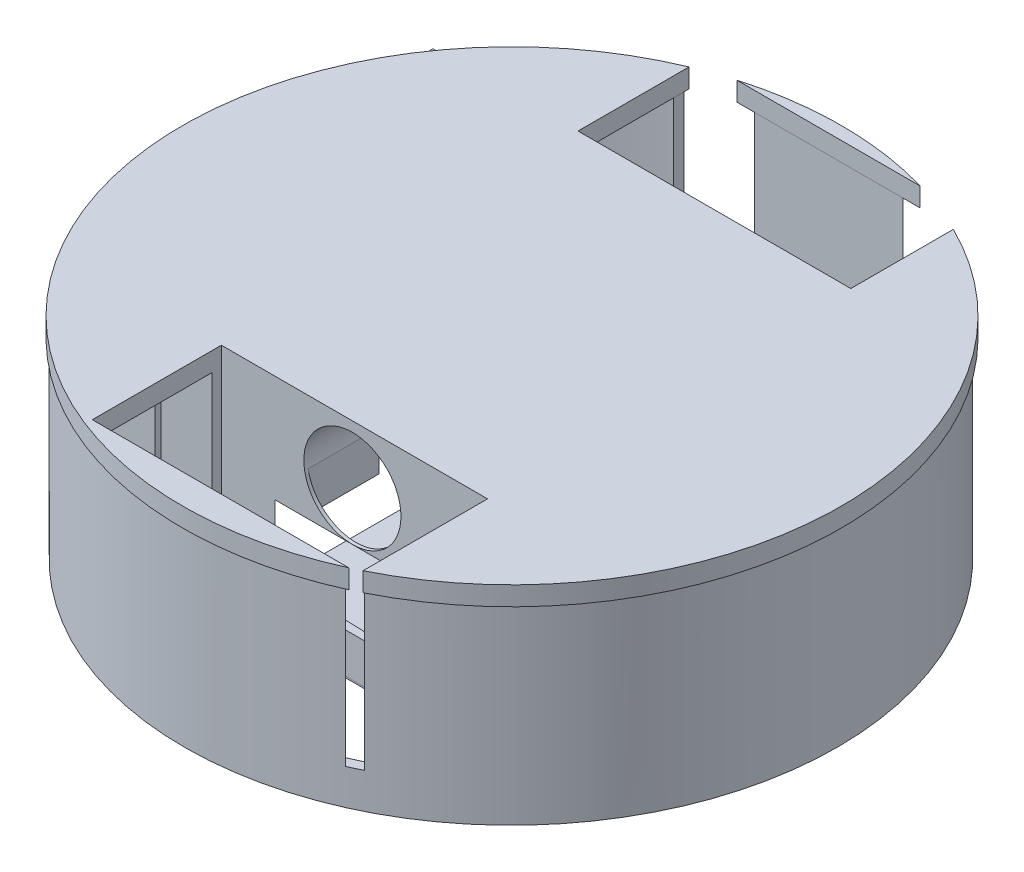
from build123d import *

# Parameters (mm, degrees)
MOTORHOLDERSSKETCH_R          = 23.41
MOTORHOLDERS_DEPTH            = 80
MOTORHOLDERS_DEPTH_BACK       = 80
SKETCH4_W                     = 262.774983374
SKETCH4_H                     = 153.112553215
CUT_EXTRUDE1_DEPTH            = 26
SKETCH6_W                     = 40.569681466
SKETCH6_H                     = 13.420779119
POWERBANKHOLDERS_DEPTH        = 30
POWERBANKHOLDERS_DEPTH_BACK   = 59
SKETCH6_W_2                   = 24.337910208
SKETCH6_H_2                   = 38.261259506
SKETCH6_W_3                   = 13.389321538
SKETCH6_H_3                   = 10.347679347
POWERBANKHOLDERS_2_DEPTH      = 30
POWERBANKHOLDERS_2_DEPTH_BACK = 59
SKETCH6_W_4                   = 55.674763771
SKETCH6_H_4                   = 37.111507406
SKETCH6_W_5                   = 12.844328805
SKETCH6_H_5                   = 18.336479725
SKETCH6_W_6                   = 12.407504742
SKETCH6_H_6                   = 16.443461188
POWERBANKHOLDERS_3_DEPTH      = 30
POWERBANKHOLDERS_3_DEPTH_BACK = 59
SKETCH6_W_7                   = 56.474336521
SKETCH6_H_7                   = 35.272094794
SKETCH6_W_8                   = 11.134493861
SKETCH6_H_8                   = 18.035399163
SKETCH6_W_9                   = 16.537391536
SKETCH6_H_9                   = 14.436538778
POWERBANKHOLDERS_4_DEPTH      = 30
POWERBANKHOLDERS_4_DEPTH_BACK = 59
SKETCH6_W_10                  = 28.150495439
SKETCH6_H_10                  = 24.933985152
SKETCH6_W_11                  = 10.177859407
SKETCH6_H_11                  = 9.83070569
POWERBANKHOLDERS_5_DEPTH      = 30
POWERBANKHOLDERS_5_DEPTH_BACK = 59
SKETCH6_W_12                  = 30.670744753
SKETCH6_H_12                  = 26.330219561
SKETCH6_W_13                  = 9.898416255
SKETCH6_H_13                  = 10.635603546
POWERBANKHOLDERS_6_DEPTH      = 30
POWERBANKHOLDERS_6_DEPTH_BACK = 59
SKETCH21_R                    = 138.5
BOTTOMPLATE_DEPTH             = 5
BOTTOMPLATE_DEPTH_BACK        = 3
SKETCH23_W                    = 82.936115801
SKETCH23_H                    = 87.063331284
MOTORMOUNTINGSUPPORT1_DEPTH   = 6
SKETCH24_W                    = 62.643465408
SKETCH24_H                    = 86.363062387
MOTORMOUNTINGSUPPOR2_DEPTH    = 6
SKETCH17_R                    = 2.1
SKETCH17_R_2                  = 7.5
MOTORHOLES1_DEPTH             = 31.5
SKETCH19_R                    = 2.1
SKETCH19_R_2                  = 7.5
CUT_EXTRUDE4_DEPTH            = 30
SKETCH29_W                    = 154.635205036
SKETCH29_H                    = 84.131588093
SKETCH29_W_2                  = 26
SKETCH29_H_2                  = 19.212652328
BOSS_EXTRUDE8_DEPTH           = 3
SKETCH28_W                    = 66.387115975
SKETCH28_H                    = 157.698901517
CELLPHONEPLATE_DEPTH          = 1.5
CELLPHONEPLATE_DEPTH_BACK     = 2.5
POWERBANKCUT_DEPTH            = 44.404272
MOTORHOLDEREXTRUDESKETCH_R    = 20.415
MOTORHOLDERCUT_DEPTH          = 77
MOTORHOLDERCUT_DEPTH_BACK     = 77
LABEL_DEPTH                   = 1
SKETCH42_R                    = 54.5
SKETCH42_R_2                  = 42
CUT_EXTRUDE10_DEPTH           = 10
CUT_EXTRUDE10_DEPTH_BACK      = 5
SKETCH43_R                    = 54.5
SKETCH43_R_2                  = 42
CUT_EXTRUDE11_DEPTH           = 5
CUT_EXTRUDE11_DEPTH_BACK      = 5
SKETCH47_R                    = 137.263845686
SKETCH47_R_2                  = 133.081286055
BOSS_EXTRUDE9_DEPTH           = 80
SKETCH46_W                    = 111.865332741
SKETCH46_H                    = 54.241690417
SKETCH46_W_2                  = 114.657260807
SKETCH46_H_2                  = 51.893411638
CUT_EXTRUDE13_DEPTH           = 65
CUT_EXTRUDE13_DEPTH_BACK      = 45


with BuildPart() as part:
    # MotorHoldersSketch → MotorHolders (new body, two sides)
    with BuildSketch(Plane.XY) as motorholders_sk:
        with Locations((170, 0)):
            Circle(MOTORHOLDERSSKETCH_R)
    extrude(amount=MOTORHOLDERS_DEPTH)
    extrude(motorholders_sk.sketch, amount=-MOTORHOLDERS_DEPTH_BACK)

    # Sketch4 → Cut-Extrude1 (cut)
    with BuildSketch(Plane(origin=(0, 0, 0), x_dir=(1, 0, 0), z_dir=(0, 1, 0))):
        with Locations((89.893628689, 0.176832173)):
            Rectangle(SKETCH4_W, SKETCH4_H)
    extrude(amount=-CUT_EXTRUDE1_DEPTH, mode=Mode.SUBTRACT)


with BuildPart() as body_2:
    # Sketch6 → PowerBankHolders (new body, two sides)
    with BuildSketch(Plane(origin=(170, -34.829272125, 0), x_dir=(-1, 0, 0), z_dir=(0, -1, 0))) as powerbankholders_sk:
        with Locations((98.656261503, 70.613788094)):
            Rectangle(SKETCH6_W, SKETCH6_H)
    extrude(amount=POWERBANKHOLDERS_DEPTH)
    extrude(powerbankholders_sk.sketch, amount=-POWERBANKHOLDERS_DEPTH_BACK)



with BuildPart() as body_3:
    # Sketch6 → PowerBankHolders 2 (new body, two sides)
    with BuildSketch(Plane(origin=(170, -34.829272125, 0), x_dir=(-1, 0, 0), z_dir=(0, -1, 0))) as powerbankholders_2_sk:
        with Locations((90.713991437, -60.661147317)):
            Rectangle(SKETCH6_W_2, SKETCH6_H_2)
        with Locations((95.188696255, -66.823906317)):
            Rectangle(SKETCH6_W_3, SKETCH6_H_3, mode=Mode.SUBTRACT)
    extrude(amount=POWERBANKHOLDERS_2_DEPTH)
    extrude(powerbankholders_2_sk.sketch, amount=-POWERBANKHOLDERS_2_DEPTH_BACK)


with BuildPart() as body_4:
    # Sketch6 → PowerBankHolders 3 (new body, two sides)
    with BuildSketch(Plane(origin=(170, -34.829272125, 0), x_dir=(-1, 0, 0), z_dir=(0, -1, 0))) as powerbankholders_3_sk:
        with Locations((47.827743092, 59.306920349)):
            Rectangle(SKETCH6_W_4, SKETCH6_H_4)
        with Locations((34.93306737, 60.00949088)):
            Rectangle(SKETCH6_W_5, SKETCH6_H_5, mode=Mode.SUBTRACT)
        with Locations((60.073413265, 59.541495334)):
            Rectangle(SKETCH6_W_6, SKETCH6_H_6, mode=Mode.SUBTRACT)
    extrude(amount=POWERBANKHOLDERS_3_DEPTH)
    extrude(powerbankholders_3_sk.sketch, amount=-POWERBANKHOLDERS_3_DEPTH_BACK)


with BuildPart() as body_5:
    # Sketch6 → PowerBankHolders 4 (new body, two sides)
    with BuildSketch(Plane(origin=(170, -34.829272125, 0), x_dir=(-1, 0, 0), z_dir=(0, -1, 0))) as powerbankholders_4_sk:
        with Locations((48.322417758, -61.807610384)):
            Rectangle(SKETCH6_W_7, SKETCH6_H_7)
        with Locations((37.73953158, -63.792391966)):
            Rectangle(SKETCH6_W_8, SKETCH6_H_8, mode=Mode.SUBTRACT)
        with Locations((59.979410768, -62.645522509)):
            Rectangle(SKETCH6_W_9, SKETCH6_H_9, mode=Mode.SUBTRACT)
    extrude(amount=POWERBANKHOLDERS_4_DEPTH)
    extrude(powerbankholders_4_sk.sketch, amount=-POWERBANKHOLDERS_4_DEPTH_BACK)


with BuildPart() as body_6:
    # Sketch6 → PowerBankHolders 5 (new body, two sides)
    with BuildSketch(Plane(origin=(170, -34.829272125, 0), x_dir=(-1, 0, 0), z_dir=(0, -1, 0))) as powerbankholders_5_sk:
        with Locations((-34.775388772, -66.976665205)):
            Rectangle(SKETCH6_W_10, SKETCH6_H_10)
        with Locations((-36.725173705, -67.894738702)):
            Rectangle(SKETCH6_W_11, SKETCH6_H_11, mode=Mode.SUBTRACT)
    extrude(amount=POWERBANKHOLDERS_5_DEPTH)
    extrude(powerbankholders_5_sk.sketch, amount=-POWERBANKHOLDERS_5_DEPTH_BACK)


with BuildPart() as body_7:
    # Sketch6 → PowerBankHolders 6 (new body, two sides)
    with BuildSketch(Plane(origin=(170, -34.829272125, 0), x_dir=(-1, 0, 0), z_dir=(0, -1, 0))) as powerbankholders_6_sk:
        with Locations((-33.722690809, 64.697564271)):
            Rectangle(SKETCH6_W_12, SKETCH6_H_12)
        with Locations((-36.585452129, 63.859928969)):
            Rectangle(SKETCH6_W_13, SKETCH6_H_13, mode=Mode.SUBTRACT)
    extrude(amount=POWERBANKHOLDERS_6_DEPTH)
    extrude(powerbankholders_6_sk.sketch, amount=-POWERBANKHOLDERS_6_DEPTH_BACK)

    # Sketch24 → MotorMountingSuppor2 (add)
    with BuildSketch(Plane(origin=(0, 0, -80), x_dir=(-1, 0, 0), z_dir=(0, 0, -1))):
        with Locations((-170.868787608, -23.94412431)):
            Rectangle(SKETCH24_W, SKETCH24_H)
    extrude(amount=-MOTORMOUNTINGSUPPOR2_DEPTH)

    # Sketch19 → Cut-Extrude4 (cut)
    with BuildSketch(Plane(origin=(0, 0, -80), x_dir=(-1, 0, 0), z_dir=(0, 0, -1))):
        with Locations((-185.5, 0)):
            Circle(SKETCH19_R)
        with Locations((-177.75, -13.42)):
            Circle(SKETCH19_R)
        with Locations((-162.25, -13.42)):
            Circle(SKETCH19_R)
        with Locations((-154.5, 0)):
            Circle(SKETCH19_R)
        with Locations((-162.25, 13.42)):
            Circle(SKETCH19_R)
        with Locations((-177.75, 13.42)):
            Circle(SKETCH19_R)
        with Locations((-170, 7)):
            Circle(SKETCH19_R_2)
    extrude(amount=-CUT_EXTRUDE4_DEPTH, mode=Mode.SUBTRACT)

    # Sketch29 → Boss-Extrude8 (add)
    with BuildSketch(Plane(origin=(219.058063185, 0, 0), x_dir=(0, 0, -1), z_dir=(1, 0, 0))):
        with Locations((-0.622085312, -21.859578752)):
            Rectangle(SKETCH29_W, SKETCH29_H)
        with Locations((-0.45071267, -38.546737855)):
            Rectangle(SKETCH29_W_2, SKETCH29_H_2, mode=Mode.SUBTRACT)
    extrude(amount=-BOSS_EXTRUDE8_DEPTH)

    # Sketch28 → CellPhonePlate (add, two sides)
    with BuildSketch(Plane(origin=(0, -64.829272125, 0), x_dir=(-1, 0, 0), z_dir=(0, -1, 0))) as cellphoneplate_sk:
        with Locations((-156.196154729, -0.699595313)):
            Rectangle(SKETCH28_W, SKETCH28_H)
    extrude(amount=CELLPHONEPLATE_DEPTH)
    extrude(cellphoneplate_sk.sketch, amount=-CELLPHONEPLATE_DEPTH_BACK)


with BuildPart() as body_2_1:
    add(body_2.part)

    add(body_3.part)  # BottomPlate merges body 3

    add(part.part)  # BottomPlate merges part

    add(body_4.part)  # BottomPlate merges body 4

    add(body_5.part)  # BottomPlate merges body 5
    # Sketch21 → BottomPlate (add, two sides)
    with BuildSketch(Plane(origin=(0, 19.575, 0), x_dir=(1, 0, 0), z_dir=(0, 1, 0))) as bottomplate_sk:
        with Locations((165.302944831, -3.6825671)):
            Circle(SKETCH21_R)
    extrude(amount=BOTTOMPLATE_DEPTH)
    extrude(bottomplate_sk.sketch, amount=-BOTTOMPLATE_DEPTH_BACK)


    add(body_6.part)  # MotorMountingSupport1 merges body 6
    # Sketch23 → MotorMountingSupport1 (add)
    with BuildSketch(Plane.XY.offset(80)):
        with Locations((162.789906406, -21.691470758)):
            Rectangle(SKETCH23_W, SKETCH23_H)
    extrude(amount=-MOTORMOUNTINGSUPPORT1_DEPTH)

    # Sketch17 → MotorHoles1 (cut)
    with BuildSketch(Plane.XY.offset(80)):
        with Locations((185.5, 0)):
            Circle(SKETCH17_R)
        with Locations((177.75, -13.42)):
            Circle(SKETCH17_R)
        with Locations((162.25, -13.42)):
            Circle(SKETCH17_R)
        with Locations((154.5, 0)):
            Circle(SKETCH17_R)
        with Locations((162.25, 13.42)):
            Circle(SKETCH17_R)
        with Locations((177.75, 13.42)):
            Circle(SKETCH17_R)
        with Locations((170, 7)):
            Circle(SKETCH17_R_2)
    extrude(amount=-MOTORHOLES1_DEPTH, mode=Mode.SUBTRACT)


with BuildPart() as powerbankcut_tool:
    # Sketch11 → PowerBankCut (new body)
    with BuildSketch(Plane(origin=(0, -20.425, 0), x_dir=(1, 0, 0), z_dir=(0, 1, 0))):
        Polygon((55.038885452, -72.893378905), (55.038885452, 75.050788564), (295.013044953, 65.256410745), (295.013044953, -80.378817854), align=None)
    extrude(amount=-POWERBANKCUT_DEPTH)


with BuildPart() as body_2_2:
    add(body_2_1.part)

    # PowerBankCut: cut by powerbankcut_tool
    add(powerbankcut_tool.part, mode=Mode.SUBTRACT)


with BuildPart() as body_7_1:
    add(body_7.part)

    # PowerBankCut: cut by powerbankcut_tool
    add(powerbankcut_tool.part, mode=Mode.SUBTRACT)


with BuildPart() as motorholdercut_tool:
    # MotorHolderExtrudeSketch → MotorHolderCut (new body, two sides)
    with BuildSketch(Plane.XY) as motorholdercut_sk:
        with Locations((170, 0)):
            Circle(MOTORHOLDEREXTRUDESKETCH_R)
    extrude(amount=MOTORHOLDERCUT_DEPTH)
    extrude(motorholdercut_sk.sketch, amount=-MOTORHOLDERCUT_DEPTH_BACK)


with BuildPart() as body_2_3:
    add(body_2_2.part)

    # MotorHolderCut: cut by motorholdercut_tool
    add(motorholdercut_tool.part, mode=Mode.SUBTRACT)


with BuildPart() as body_7_2:
    add(body_7_1.part)

    # MotorHolderCut: cut by motorholdercut_tool
    add(motorholdercut_tool.part, mode=Mode.SUBTRACT)

    # Sketch31 → Label (add)
    with BuildSketch(Plane(origin=(219.058063185, 0, 0), x_dir=(0, 0, -1), z_dir=(1, 0, 0))):
        Polygon((49.44174371, -6.192727454), (49.44174371, -19.373871934), (42.934240846, -21.634082149), (40.061775134, -21.634082149), (37.786330287, -19.358637302), (37.786330287, -15.381348839), (40.061775134, -13.105903993), (37.786330287, -6.554538213), (41.49800799, -6.554538213), (43.400438848, -12.031937694), (46.389004897, -12.031937694), (46.389004897, -6.554538213), align=None)
        Polygon((46.389004897, -17.885685432), (46.389004897, -14.591500132), (41.49800799, -14.591500132), (39.506689527, -16.25408163), (41.565563867, -18.720050661), align=None, mode=Mode.SUBTRACT)
        Polygon((33.019279212, -21.634082149), (33.019279212, -9.830221103), (30.540166598, -7.351108489), (25.720297263, -7.351108489), (23.241184649, -9.830221103), (23.241184649, -21.634082149), (25.720297263, -21.634082149), (25.720297263, -10.745357897), (30.540166598, -10.745357897), (30.540166598, -21.634082149), align=None)
        Polygon((19.722613698, -8.590664796), (19.722613698, -21.634082149), (13.820683175, -15.732151626), (13.820683175, -21.634082149), (10.7708131, -21.634082149), (10.7708131, -8.590664796), (16.771648437, -14.591500132), (16.771648437, -8.590664796), align=None)
        Polygon((7.38910922, -8.590664796), (7.38910922, -21.634082149), (3.728231084, -21.634082149), (1.320922213, -17.369993071), (-1.251934103, -21.634082149), (-3.655389162, -21.634082149), (-4.691643117, -8.590664796), (-2.453661633, -8.590664796), (0.034494055, -15.754458747), (1.320922213, -13.622414208), (4.854437776, -15.754458747), (4.854437776, -8.590664796), align=None)
        Polygon((-7.682306608, -21.634082149), (-10.987514091, -15.754458747), (-10.987514091, -8.590664796), (-15.310206688, -8.590664796), (-15.310206688, -15.754458747), (-19.269516545, -21.634082149), (-15.310206688, -21.634082149), (-13.148860389, -18.424456549), (-10.987514091, -22.269268816), align=None)
        Polygon((-22.571010896, -8.590664796), (-22.098919416, -21.634082149), (-26.491509787, -21.634082149), (-29.911637517, -19.358637302), (-30.635996911, -15.754458747), (-27.413487689, -14.105212159), (-30.635996911, -8.590664796), (-27.413487689, -8.590664796), (-25.398720895, -14.105212159), (-24.295214602, -14.105212159), (-24.494807297, -8.590664796), align=None)
        Polygon((-24.295214602, -19.358637302), (-24.295214602, -16.25408163), (-26.491509787, -16.25408163), (-27.413487689, -17.176059532), (-27.413487689, -18.424456549), (-26.333852082, -19.504092156), align=None, mode=Mode.SUBTRACT)
        Polygon((-35.009913233, -8.590664796), (-38.639456152, -8.590664796), (-41.524071596, -13.622414208), (-41.524071596, -18.424456549), (-38.639456152, -21.309071994), (-35.009913233, -21.309071994), (-32.497839278, -18.796998039), (-32.497839278, -14.105212159), align=None)
        Polygon((-36.111415057, -18.796998039), (-34.718122355, -17.403705336), (-34.718122355, -13.105903993), (-36.662704643, -11.161321704), (-37.865915536, -11.161321704), (-39.310718257, -13.105903993), (-39.515454652, -16.854377093), (-38.250007481, -18.720050661), align=None, mode=Mode.SUBTRACT)
        Polygon((-44.059291997, -21.309071994), (-44.059291997, -8.590664796), (-49.449943726, -8.590664796), (-52.226947095, -11.367668165), (-52.226947095, -14.105212159), (-50.577700506, -15.754458747), (-52.226947095, -17.403705336), (-52.226947095, -19.358637302), (-49.449943726, -21.309071994), align=None)
        Polygon((-46.243610757, -16.854377093), (-48.903166093, -16.854377093), (-49.449943726, -18.424456549), (-48.083567545, -19.358637302), (-46.243610757, -19.358637302), align=None, mode=Mode.SUBTRACT)
        Polygon((-45.920604156, -14.591500132), (-45.920604156, -11.161321704), (-49.210466936, -10.745357897), (-50.175617033, -12.876410918), (-48.58914421, -14.591500132), align=None, mode=Mode.SUBTRACT)
        Polygon((-57.797660681, -21.309071994), (-55.60105832, -19.112469633), (-55.60105832, -10.745357897), (-59.263729006, -8.590664796), (-61.781771114, -8.590664796), (-63.936464214, -10.745357897), (-63.936464214, -19.112469633), (-61.781771114, -21.267162733), align=None)
        Polygon((-58.567152612, -18.720050661), (-57.797660681, -17.403705336), (-57.797660681, -11.763595566), (-59.657270857, -10.745357897), (-60.814447819, -10.745357897), (-62.101027616, -12.031937694), (-61.781771114, -17.403705336), (-60.814447819, -18.720050661), align=None, mode=Mode.SUBTRACT)
        Polygon((-66.791767957, -21.267162733), (-74.870531799, -21.267162733), (-74.870531799, -19.112469633), (-72.266477292, -19.112469633), (-72.266477292, -8.590664796), (-69.997684236, -8.590664796), (-69.997684236, -19.112469633), (-66.791767957, -19.112469633), align=None)
    extrude(amount=LABEL_DEPTH)

    # Sketch42 → Cut-Extrude10 (cut, two sides)
    with BuildSketch(Plane.XY.offset(80)) as cut_extrude10_sk:
        with Locations((170, 7)):
            Circle(SKETCH42_R)
        with Locations((170, 7)):
            Circle(SKETCH42_R_2, mode=Mode.SUBTRACT)
    extrude(amount=CUT_EXTRUDE10_DEPTH, mode=Mode.SUBTRACT)
    extrude(cut_extrude10_sk.sketch, amount=-CUT_EXTRUDE10_DEPTH_BACK, mode=Mode.SUBTRACT)

    # Sketch43 → Cut-Extrude11 (cut, two sides)
    with BuildSketch(Plane(origin=(0, 0, -80), x_dir=(-1, 0, 0), z_dir=(0, 0, -1))) as cut_extrude11_sk:
        with Locations((-170, 7)):
            Circle(SKETCH43_R)
        with Locations((-170, 7)):
            Circle(SKETCH43_R_2, mode=Mode.SUBTRACT)
    extrude(amount=CUT_EXTRUDE11_DEPTH, mode=Mode.SUBTRACT)
    extrude(cut_extrude11_sk.sketch, amount=-CUT_EXTRUDE11_DEPTH_BACK, mode=Mode.SUBTRACT)


with BuildPart() as body_3_2:
    # Sketch47 → Boss-Extrude9 (new body)
    with BuildSketch(Plane.XZ.offset(-16.575)):
        with Locations((165.466984252, 4.321723304)):
            Circle(SKETCH47_R)
        with Locations((165.466984252, 4.321723304)):
            Circle(SKETCH47_R_2, mode=Mode.SUBTRACT)
    extrude(amount=BOSS_EXTRUDE9_DEPTH)


with BuildPart() as cut_extrude13_tool:
    # Sketch46 → Cut-Extrude13 (new body, two sides)
    with BuildSketch(Plane.XZ.offset(-16.575)) as cut_extrude13_sk:
        with Locations((170.860752277, 102.584514521)):
            Rectangle(SKETCH46_W, SKETCH46_H)
        with Locations((169.250548927, -103.394116766)):
            Rectangle(SKETCH46_W_2, SKETCH46_H_2)
    extrude(amount=CUT_EXTRUDE13_DEPTH)
    extrude(cut_extrude13_sk.sketch, amount=-CUT_EXTRUDE13_DEPTH_BACK)


with BuildPart() as body_2_4:
    add(body_2_3.part)

    # Cut-Extrude13: cut by cut_extrude13_tool
    add(cut_extrude13_tool.part, mode=Mode.SUBTRACT)


with BuildPart() as body_7_3:
    add(body_7_2.part)

    # Cut-Extrude13: cut by cut_extrude13_tool
    add(cut_extrude13_tool.part, mode=Mode.SUBTRACT)


with BuildPart() as body_3_2_1:
    add(body_3_2.part)

    # Cut-Extrude13: cut by cut_extrude13_tool
    add(cut_extrude13_tool.part, mode=Mode.SUBTRACT)


solid = Compound([body_2_4.part, body_7_3.part, body_3_2_1.part])
